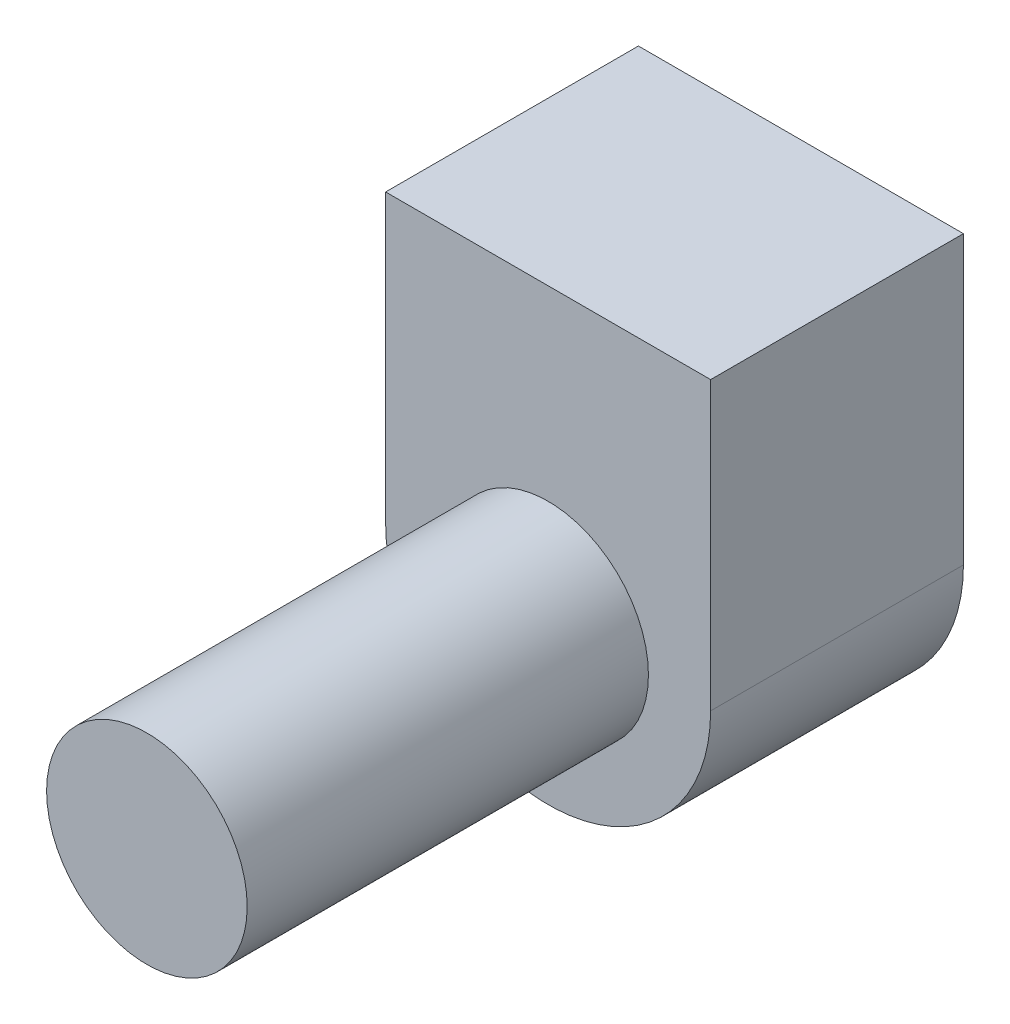
from build123d import *

# Parameters (mm, degrees)
BOSS_EXTRUDE1_DEPTH = 8.001
SKETCH2_R           = 6.35
BOSS_EXTRUDE2_DEPTH = 25.4


with BuildPart() as part:
    # Sketch1 → Boss-Extrude1 (new, symmetric)
    with BuildSketch(Plane.XY):
        with BuildLine():
            Line((-10.287, 0), (10.287, 0))
            Line((10.287, 0), (10.287, -18.161))
            ThreePointArc((10.287, -18.161), (0, -28.448), (-10.287, -18.161))
            Line((-10.287, -18.161), (-10.287, 0))
        make_face()
    extrude(amount=BOSS_EXTRUDE1_DEPTH, both=True)

    # Sketch2 → Boss-Extrude2 (add)
    with BuildSketch(Plane.XY.offset(8.001)):
        with Locations((0, -18.161)):
            Circle(SKETCH2_R)
    extrude(amount=BOSS_EXTRUDE2_DEPTH)


solid = part.part
